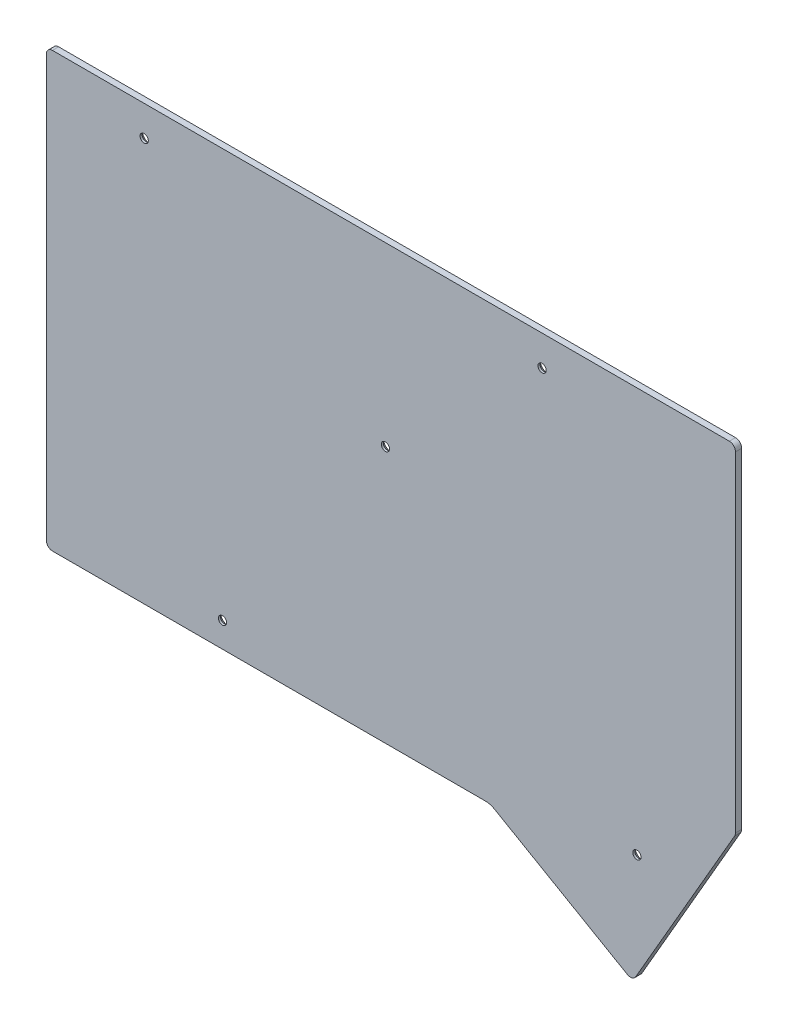
from build123d import *

# Parameters (mm, degrees)
SKETCH1_R           = 1
BOSS_EXTRUDE1_DEPTH = 1.5
CHAMFER1_SIZE       = 1


with BuildPart() as part:
    # Sketch1 → Boss-Extrude1 (new body)
    with BuildSketch(Plane.XY):
        with BuildLine():
            Line((20.7161288, 151.924941972), (-143.43387189, 151.924941972))
            ThreePointArc((-143.43387189, 151.924941972), (-144.494532062, 151.485602143), (-144.93387189, 150.424941972))
            Line((-144.93387189, 150.424941972), (-144.93387189, 48.261817052))
            ThreePointArc((-144.93387189, 48.261817052), (-144.494532062, 47.20115688), (-143.43387189, 46.761817052))
            Line((-143.43387189, 46.761817052), (-38.493629317, 46.761817052))
            ThreePointArc((-38.493629317, 46.761817052), (-37.328943614, 46.60848327), (-36.243629317, 46.158931369))
            Line((-36.243629317, 46.158931369), (-4.017847382, 27.553367493))
            ThreePointArc((-4.017847382, 27.553367493), (-2.879618836, 27.403516854), (-1.968809299, 28.10240556))
            Line((-1.968809299, 28.10240556), (22.015166883, 69.64386796))
            ThreePointArc((22.015166883, 69.64386796), (22.165017534, 70.005639409), (22.2161288, 70.393867999))
            Line((22.2161288, 70.393867999), (22.2161288, 150.424941972))
            ThreePointArc((22.2161288, 150.424941972), (21.776788972, 151.485602143), (20.7161288, 151.924941972))
        make_face()
        with Locations((-24.69657117, 144.575050352)):
            Circle(SKETCH1_R, mode=Mode.SUBTRACT)
        with Locations((-121.19657121, 144.575050352)):
            Circle(SKETCH1_R, mode=Mode.SUBTRACT)
        with Locations((-62.69657137, 109.075050232)):
            Circle(SKETCH1_R, mode=Mode.SUBTRACT)
        with Locations((-102.19657111, 52.825050972)):
            Circle(SKETCH1_R, mode=Mode.SUBTRACT)
        with Locations((-1.69657145, 53.825048972)):
            Circle(SKETCH1_R, mode=Mode.SUBTRACT)
    extrude(amount=BOSS_EXTRUDE1_DEPTH)

    # Chamfer1
    chamfer1_edges = [part.edges().sort_by_distance(p)[0] for p in [
        (-25.69657117, 144.575050352, 0),
        (-122.19657121, 144.575050352, 0),
        (-63.69657137, 109.075050232, 0),
        (-103.19657111, 52.825050972, 0),
        (-2.69657145, 53.825048972, 0),
    ]]
    chamfer(chamfer1_edges, length=CHAMFER1_SIZE)


solid = part.part
